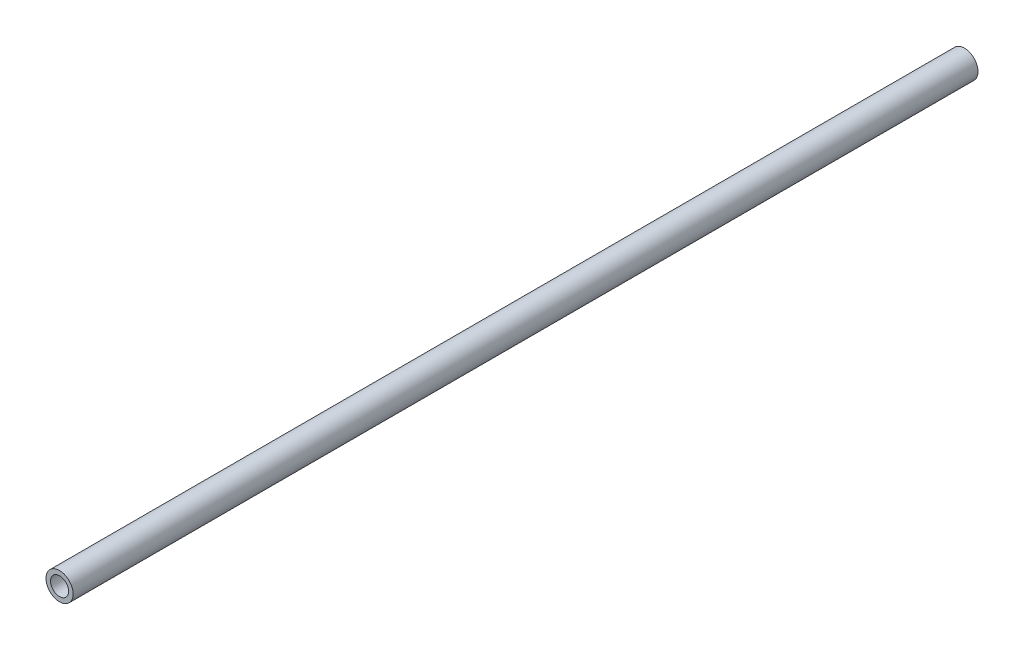
from build123d import *

# Parameters (mm, degrees)
SKETCH1_R           = 15
SKETCH1_R_2         = 10
BOSS_EXTRUDE1_DEPTH = 1000


with BuildPart() as part:
    # Sketch1 → Boss-Extrude1 (new body)
    with BuildSketch(Plane.XY):
        Circle(SKETCH1_R)
        Circle(SKETCH1_R_2, mode=Mode.SUBTRACT)
    extrude(amount=BOSS_EXTRUDE1_DEPTH)


solid = part.part
